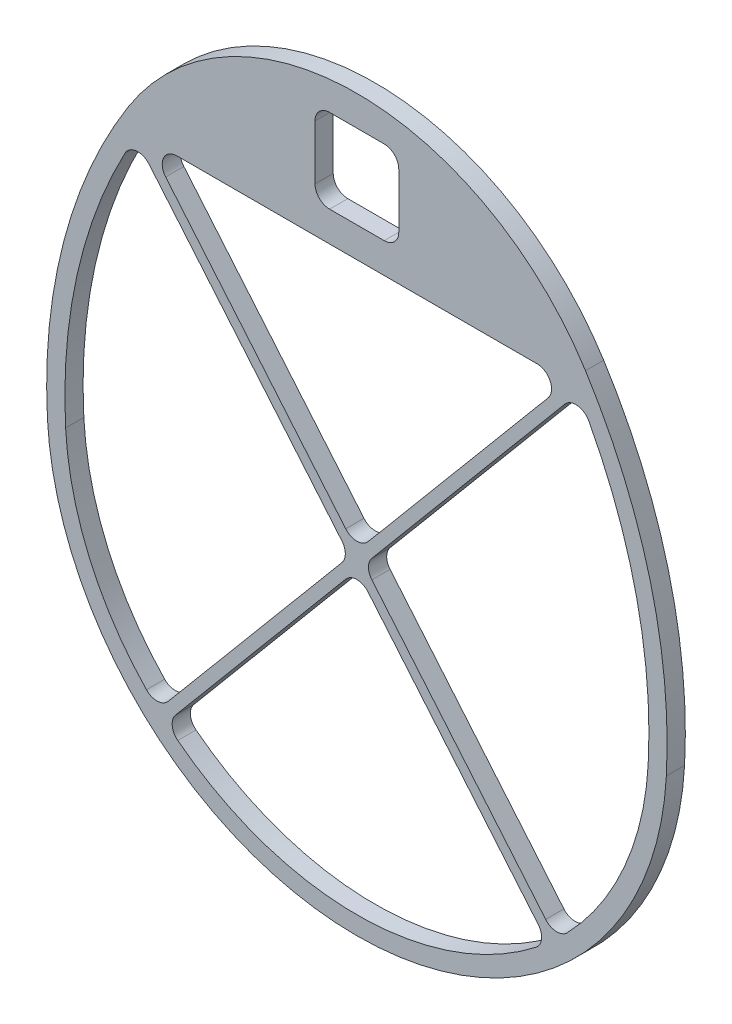
from build123d import *

# Parameters (mm, degrees)
BOSS_EXTRUDE1_DEPTH = 6.35
CUT_EXTRUDE1_REACH  = 8.35
SKETCH2_W           = 29.21
SKETCH2_H           = 29.21
FILLET1_R           = 5.08
BOSS_EXTRUDE2_DEPTH = 6.35
FILLET2_R           = 5.08


with BuildPart() as part:
    # Sketch1 → Boss-Extrude1 (new body)
    with BuildSketch(Plane.XY):
        with BuildLine():
            ThreePointArc((-79.739479369, 107.95), (-102.265174294, 55.997788823), (-107.940757138, -0.342489287))
            ThreePointArc((-107.940757138, -0.342489287), (0, -102.610284874), (107.940757138, -0.342489287))
            ThreePointArc((107.940757138, -0.342489287), (102.265174294, 55.997788823), (79.739479369, 107.95))
            ThreePointArc((79.739479369, 107.95), (0, 151.891393684), (-79.739479369, 107.95))
        make_face()
        with BuildLine():
            Line((-76.2, 101.6), (76.2, 101.6))
            ThreePointArc((76.2, 101.6), (96.55013665, 52.712534163), (101.6, 0))
            ThreePointArc((101.6, 0), (0, -96.260283012), (-101.6, 0))
            ThreePointArc((-101.6, 0), (-96.55013665, 52.712534163), (-76.2, 101.6))
        make_face(mode=Mode.SUBTRACT)
    extrude(amount=BOSS_EXTRUDE1_DEPTH)

    # Sketch2 → Cut-Extrude1 (cut, up to next)
    with BuildSketch(Plane.XY.offset(6.35), mode=Mode.PRIVATE) as cut_extrude1_sk1:
        with Locations((0, 126.745696842)):
            Rectangle(SKETCH2_W, SKETCH2_H)
    cut_extrude1_tool1 = extrude(cut_extrude1_sk1.sketch, amount=-CUT_EXTRUDE1_REACH, mode=Mode.PRIVATE) & part.part
    add(cut_extrude1_tool1.solids().sort_by_distance((0, 126.745697, 6.35))[0], mode=Mode.SUBTRACT)

    # Fillet1
    fillet1_edges = [part.edges().sort_by_distance(p)[0] for p in [
        (14.605, 141.350696842, 3.175),
        (14.605, 112.140696842, 3.175),
        (-14.605, 112.140696842, 3.175),
        (-14.605, 141.350696842, 3.175),
    ]]
    fillet(fillet1_edges, radius=FILLET1_R)

    # Sketch3 → Boss-Extrude2 (add)
    with BuildSketch(Plane.XY.offset(6.35)):
        Polygon((-77.659314664, 100.375489604), (69.28193291, -74.742270093), (72.200562238, -72.293249301), (-74.740685336, 102.824510396), align=None)
        Polygon((74.740685336, 102.824510396), (-72.200562238, -72.293249301), (-69.28193291, -74.742270093), (77.659314664, 100.375489604), align=None)
    extrude(amount=-BOSS_EXTRUDE2_DEPTH)

    # Fillet2
    fillet2_edges = [part.edges().sort_by_distance(p)[0] for p in [
        (73.713199114, 101.6, 3.175),
        (0, 13.752030134, 3.175),
        (-73.713199114, 101.6, 3.175),
        (-77.233836777, 99.868424803, 3.175),
        (-2.486800886, 10.788376244, 3.175),
        (-69.382552816, -68.934876448, 3.175),
        (-66.545991735, -71.481702369, 3.175),
        (0, 7.824722354, 3.175),
        (66.545991735, -71.481702369, 3.175),
        (69.382552816, -68.934876448, 3.175),
        (2.486800886, 10.788376244, 3.175),
        (77.233836777, 99.868424803, 3.175),
    ]]
    fillet(fillet2_edges, radius=FILLET2_R)


solid = part.part
